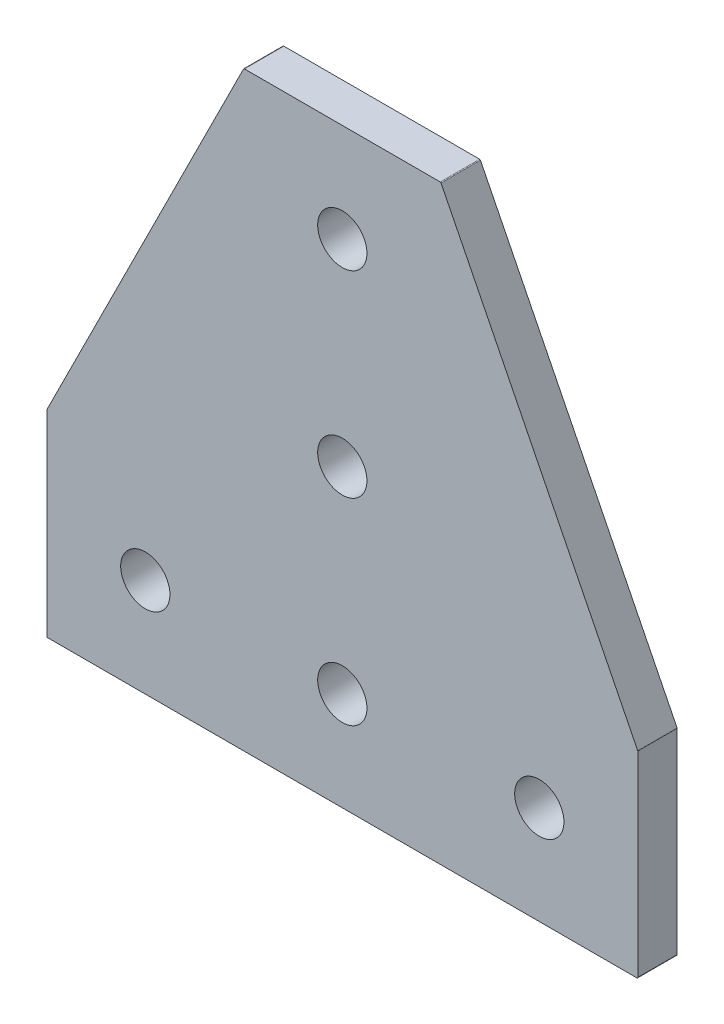
from build123d import *

# Parameters (mm, degrees)
BOSS_EXTRUDE1_DEPTH = 4
SKETCH2_R           = 2.5
CUT_EXTRUDE1_DEPTH  = 4
LPATTERN1_COUNT     = 3
LPATTERN1_PITCH     = 20
SKETCH3_R           = 2.5
CUT_EXTRUDE2_DEPTH  = 4
FILLET1_R           = 0.1


with BuildPart() as part:
    # Sketch1 → Boss-Extrude1 (new body)
    with BuildSketch(Plane.XY):
        Polygon((20, 60), (40, 60), (60, 20), (60, 0), (0, 0), (0, 20), align=None)
    extrude(amount=-BOSS_EXTRUDE1_DEPTH)

    # Sketch2 → Cut-Extrude1 (cut)
    with BuildSketch(Plane.XY):
        with Locations((30, 10)):
            Circle(SKETCH2_R)
    cut_extrude1 = extrude(amount=-CUT_EXTRUDE1_DEPTH, mode=Mode.SUBTRACT)

    # LPattern1: Cut-Extrude1 ×3
    with Locations(*[(0, i * LPATTERN1_PITCH, 0) for i in range(1, LPATTERN1_COUNT)]):
        add(cut_extrude1, mode=Mode.SUBTRACT)

    # Sketch3 → Cut-Extrude2 (cut)
    with BuildSketch(Plane.XY):
        with Locations((10, 10)):
            Circle(SKETCH3_R)
        with Locations((50, 10)):
            Circle(SKETCH3_R)
    extrude(amount=-CUT_EXTRUDE2_DEPTH, mode=Mode.SUBTRACT)

    # Fillet1
    fillet1_edges = [part.edges().sort_by_distance(p)[0] for p in [
        (0, 0, -2),
        (0, 20, -2),
        (20, 60, -2),
        (40, 60, -2),
        (60, 20, -2),
        (60, 0, -2),
    ]]
    fillet(fillet1_edges, radius=FILLET1_R)


solid = part.part
